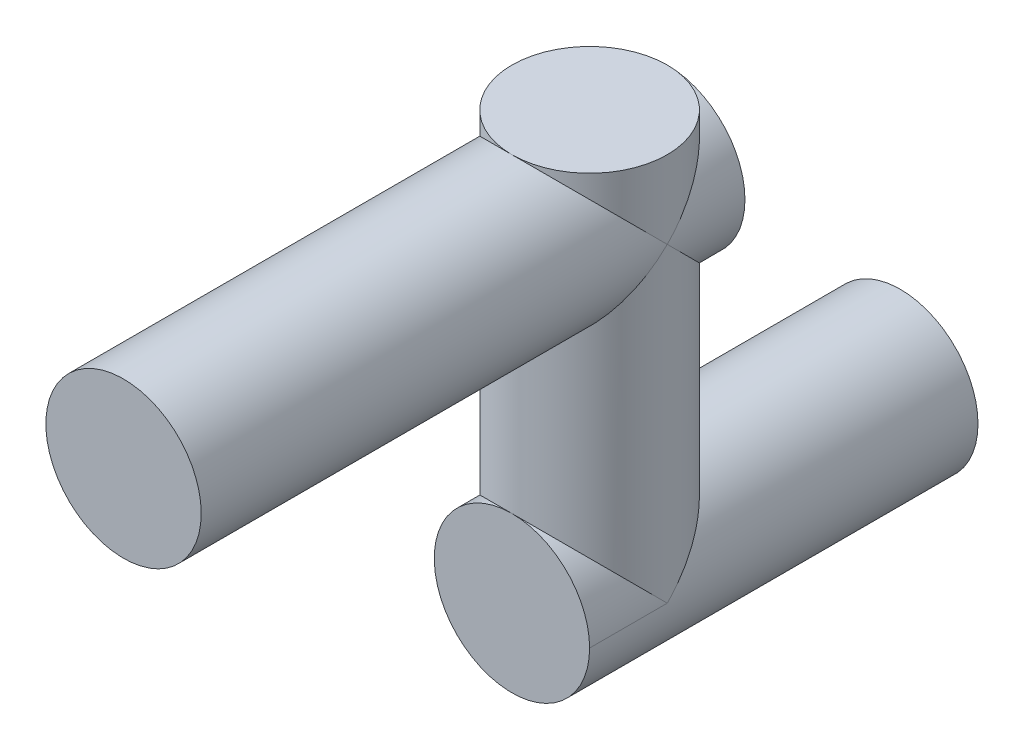
from build123d import *
from build123d.topology import SkipClean

# Parameters (mm, degrees)
SKETCH1_R           = 10
BOSS_EXTRUDE1_DEPTH = 50
SKETCH2_R           = 10
BOSS_EXTRUDE2_DEPTH = 50
BOSS_EXTRUDE3_START = 30
SKETCH4_R           = 10
BOSS_EXTRUDE3_DEPTH = 70


with BuildPart() as part:
    # Sketch1 → Boss-Extrude1 (new body)
    with BuildSketch(Plane.XY):
        Circle(SKETCH1_R)
    extrude(amount=BOSS_EXTRUDE1_DEPTH)

    # Sketch2 → Boss-Extrude2 (add)
    with SkipClean():  # the faces are left unmerged after this step: merging them gives an invalid solid
        with BuildSketch(Plane(origin=(0, 0, 0), x_dir=(1, 0, 0), z_dir=(0, 1, 0))):
            with Locations((0, -40)):
                Circle(SKETCH2_R)
        extrude(amount=BOSS_EXTRUDE2_DEPTH)

    # Sketch4 → Boss-Extrude3 (add)
    with SkipClean():  # the faces are left unmerged after this step: merging them gives an invalid solid
        with BuildSketch(Plane.XY.offset(BOSS_EXTRUDE3_START)):
            with Locations((0, 40)):
                Circle(SKETCH4_R)
        extrude(amount=BOSS_EXTRUDE3_DEPTH)


solid = part.part
